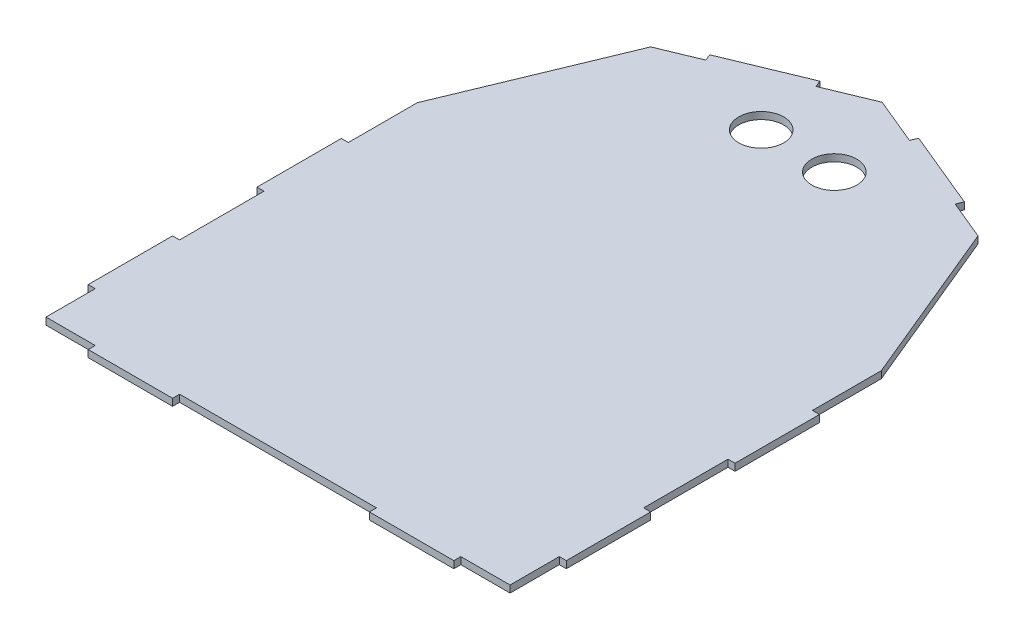
from build123d import *

# Parameters (mm, degrees)
BOSS_EXTRUDE1_DEPTH = 2.5
SKETCH6_W           = 70
SKETCH6_H           = 2.5
SKETCH6_W_2         = 2.5
SKETCH6_H_2         = 30
CUT_EXTRUDE3_DEPTH  = 3.5
SKETCH7_R           = 8
CUT_EXTRUDE4_DEPTH  = 3.5


with BuildPart() as part:
    # Sketch2 → Boss-Extrude1 (new body)
    with BuildSketch(Plane(origin=(0, 0, 0), x_dir=(1, 0, 0), z_dir=(0, 1, 0))):
        Polygon((0, 0), (170, 0), (170, 135), (145.104076401, 195.104076401), (85, 220), (24.895923599, 195.104076401), (0, 135), align=None)
    extrude(amount=BOSS_EXTRUDE1_DEPTH)

    # Sketch6 → Cut-Extrude3 (cut, through all)
    with BuildSketch(Plane(origin=(0, 2.5, 0), x_dir=(1, 0, 0), z_dir=(0, 1, 0))):
        with Locations((85, 1.25)):
            Rectangle(SKETCH6_W, SKETCH6_H)
        Polygon((170, 0), (170, 20), (167.5, 20), (167.5, 2.5), (150, 2.5), (150, 0), align=None)
        Polygon((145.104076401, 195.104076401), (130.289174832, 201.240609556), (129.332466251, 198.930910725), (143.190659239, 193.190659239), (167.5, 134.502719082), (167.5, 110), (170, 110), (170, 135), align=None)
        with Locations((168.75, 65)):
            Rectangle(SKETCH6_W_2, SKETCH6_H_2)
        Polygon((101.616080276, 210.411413695), (102.572788857, 212.721112527), (85, 220), (67.427211143, 212.721112527), (68.383919724, 210.411413695), (85, 217.294019499), align=None)
        Polygon((0, 110), (0, 135), (24.895923599, 195.104076401), (39.710825168, 201.240609556), (40.667533749, 198.930910725), (26.809340761, 193.190659239), (2.5, 134.502719082), (2.5, 110), align=None)
        with Locations((1.25, 65)):
            Rectangle(SKETCH6_W_2, SKETCH6_H_2)
        Polygon((20, 0), (0, 0), (0, 20), (2.5, 20), (2.5, 2.5), (20, 2.5), align=None)
    extrude(amount=-CUT_EXTRUDE3_DEPTH, mode=Mode.SUBTRACT)

    # Sketch7 → Cut-Extrude4 (cut, through all)
    with BuildSketch(Plane(origin=(0, 2.5, 0), x_dir=(1, 0, 0), z_dir=(0, 1, 0))):
        with Locations((72, 187.294019499)):
            Circle(SKETCH7_R)
        with Locations((98, 187.294019499)):
            Circle(SKETCH7_R)
    extrude(amount=-CUT_EXTRUDE4_DEPTH, mode=Mode.SUBTRACT)


solid = part.part
